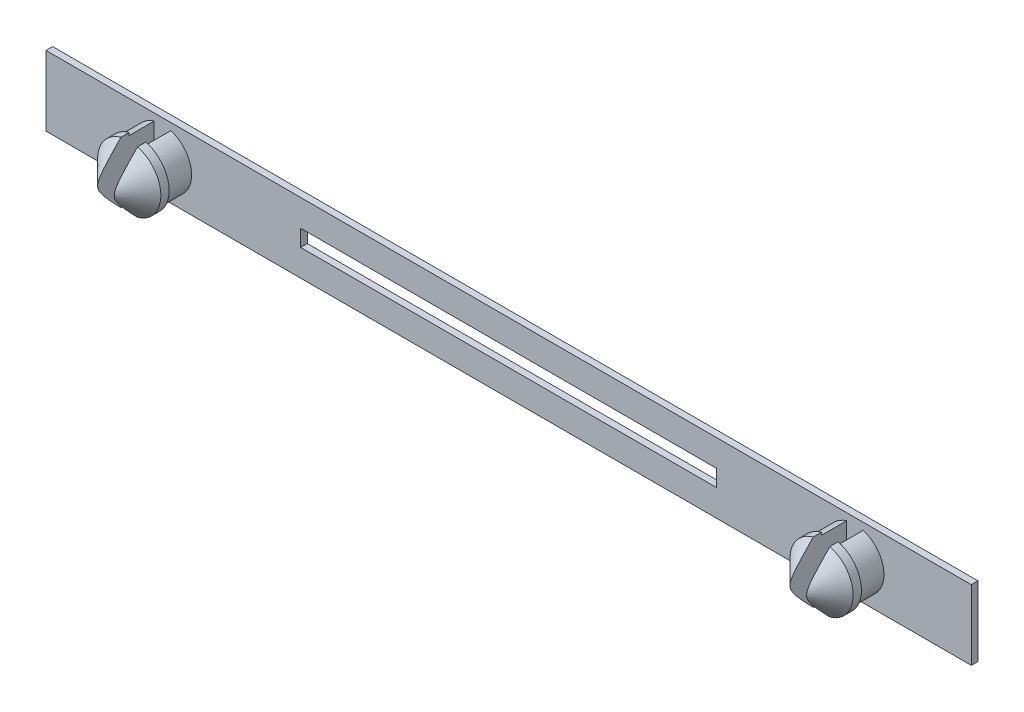
from build123d import *

# Parameters (mm, degrees)
SKICA2_W                 = 55.6
SKICA2_H                 = 4.2
SKICA2_W_2               = 25
SKICA2_H_2               = 1
P_IDAT_VYSUNUT_M2_DEPTH  = 0.4
SKICA3_R                 = 1.75
P_IDAT_VYSUNUT_M3_DEPTH  = 1.5
SKICA5_R                 = 1.9
P_IDAT_VYSUNUT_M5_DEPTH  = 2
ZKOSEN_2_SIZE            = 1.5
SKICA7_W                 = 1
SKICA7_H                 = 5
ODEBRAT_VYSUNUT_M1_DEPTH = 3.5


with BuildPart() as part:
    # Skica2 → Přidat vysunutím2 (new body)
    with BuildSketch(Plane.XY):
        Rectangle(SKICA2_W, SKICA2_H)
        Rectangle(SKICA2_W_2, SKICA2_H_2, mode=Mode.SUBTRACT)
    extrude(amount=P_IDAT_VYSUNUT_M2_DEPTH)

    # Skica3 → Přidat vysunutím3 (add)
    with BuildSketch(Plane.XY.offset(0.4)):
        with Locations((-20.8, 0)):
            Circle(SKICA3_R)
        with Locations((20.8, 0)):
            Circle(SKICA3_R)
    extrude(amount=P_IDAT_VYSUNUT_M3_DEPTH)

    # Skica5 → Přidat vysunutím5 (add)
    with BuildSketch(Plane.XY.offset(1.9)):
        with Locations((-20.8, 0)):
            Circle(SKICA5_R)
        with Locations((20.8, 0)):
            Circle(SKICA5_R)
    extrude(amount=P_IDAT_VYSUNUT_M5_DEPTH)

    # Zkosení2
    zkosen_2_edges = [part.edges().sort_by_distance(p)[0] for p in [
        (-22.7, 0, 3.9),
        (18.9, 0, 3.9),
    ]]
    chamfer(zkosen_2_edges, length=ZKOSEN_2_SIZE)

    # Skica7 → Odebrat vysunutím1 (cut)
    with BuildSketch(Plane.XY.offset(3.9)):
        with Locations((-20.8, 0)):
            Rectangle(SKICA7_W, SKICA7_H)
        with Locations((20.8, 0)):
            Rectangle(SKICA7_W, SKICA7_H)
    extrude(amount=-ODEBRAT_VYSUNUT_M1_DEPTH, mode=Mode.SUBTRACT)


solid = part.part
